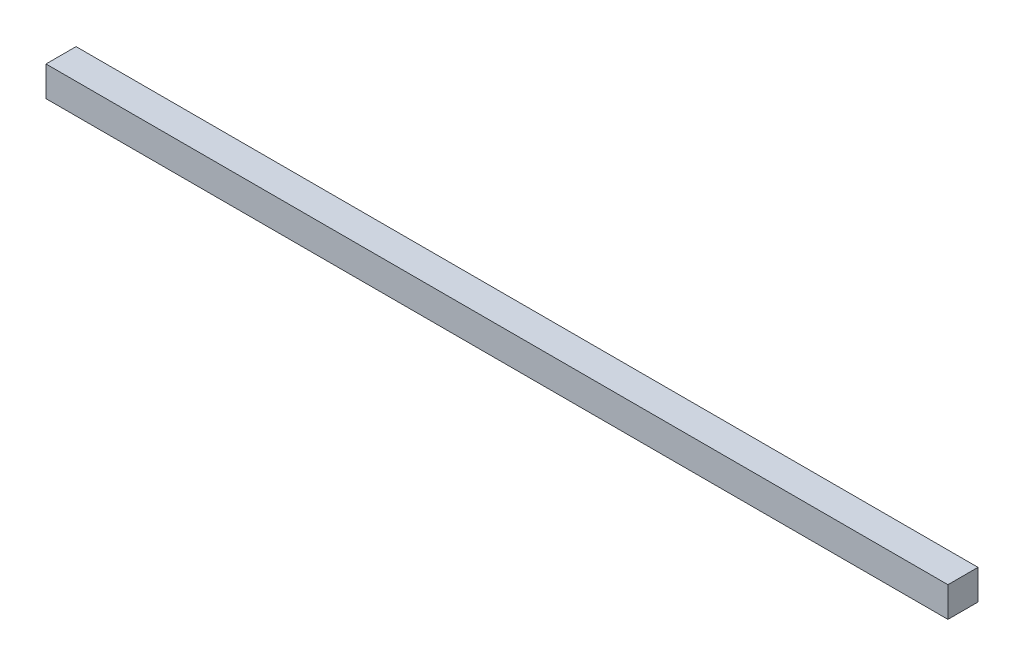
from build123d import *

# Parameters (mm, degrees)
SKETCH1_W           = 600
SKETCH1_H           = 20
BOSS_EXTRUDE1_DEPTH = 20


with BuildPart() as part:
    # Sketch1 → Boss-Extrude1 (new body)
    with BuildSketch(Plane(origin=(0, 0, 0), x_dir=(1, 0, 0), z_dir=(0, 1, 0))):
        Rectangle(SKETCH1_W, SKETCH1_H)
    extrude(amount=BOSS_EXTRUDE1_DEPTH)


solid = part.part
